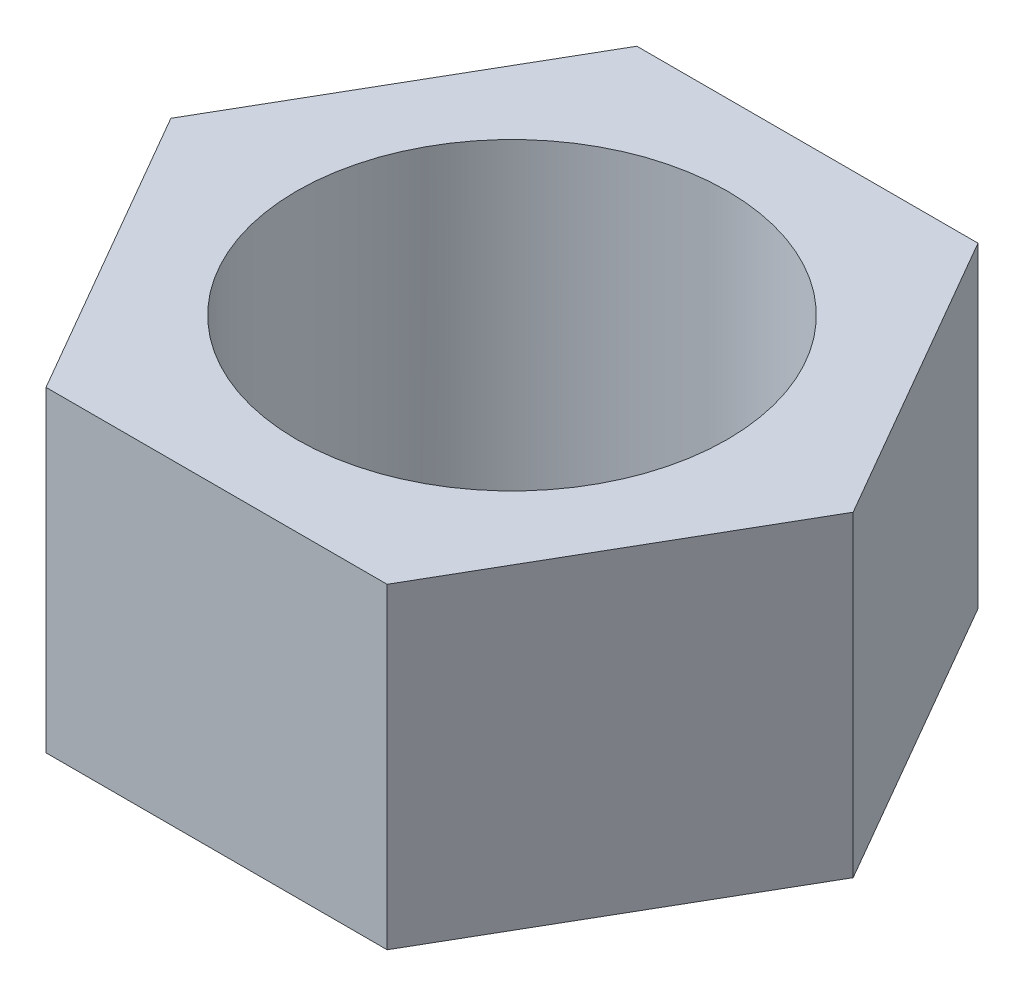
from build123d import *

# Parameters (mm, degrees)
BOSS_EXTRUDE1_DEPTH = 3.75
SKETCH3_R           = 2.55
CUT_EXTRUDE1_DEPTH  = 10


with BuildPart() as part:
    # Sketch1 → Boss-Extrude1 (new body)
    with BuildSketch(Plane(origin=(0, 0, 0), x_dir=(1, 0, 0), z_dir=(0, 1, 0))):
        Polygon((4.041451884, 0), (2.020725942, 3.5), (-2.020725942, 3.5), (-4.041451884, 0), (-2.020725942, -3.5), (2.020725942, -3.5), align=None)
    extrude(amount=BOSS_EXTRUDE1_DEPTH)

    # Sketch3 → Cut-Extrude1 (cut)
    with BuildSketch(Plane.XZ):
        Circle(SKETCH3_R)
    extrude(amount=-CUT_EXTRUDE1_DEPTH, mode=Mode.SUBTRACT)


solid = part.part
